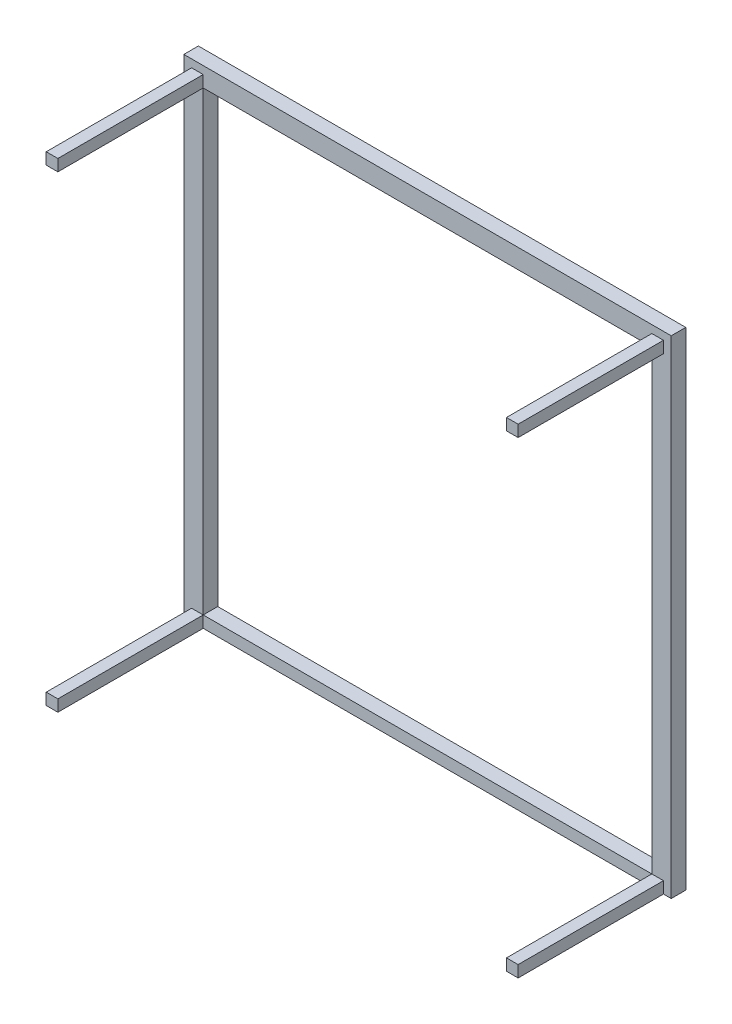
from build123d import *

# Parameters (mm, degrees)
SKETCH1_W           = 503
SKETCH1_H           = 503
SKETCH1_W_2         = 463
SKETCH1_H_2         = 471
BOSS_EXTRUDE1_DEPTH = 15
SKETCH2_W           = 12
SKETCH2_H           = 12
BOSS_EXTRUDE2_DEPTH = 200
SKETCH3_W           = 487
SKETCH3_H           = 495
CUT_EXTRUDE1_DEPTH  = 50


with BuildPart() as part:
    # Sketch1 → Boss-Extrude1 (new body)
    with BuildSketch(Plane.XY):
        with Locations((251.5, 251.5)):
            Rectangle(SKETCH1_W, SKETCH1_H)
        with Locations((251.5, 247.5)):
            Rectangle(SKETCH1_W_2, SKETCH1_H_2, mode=Mode.SUBTRACT)
    extrude(amount=BOSS_EXTRUDE1_DEPTH)

    # Sketch2 → Boss-Extrude2 (add)
    with BuildSketch(Plane.XY.offset(15)):
        with Locations((14, 489)):
            Rectangle(SKETCH2_W, SKETCH2_H)
        with Locations((489, 489)):
            Rectangle(SKETCH2_W, SKETCH2_H)
        with Locations((14, 6)):
            Rectangle(SKETCH2_W, SKETCH2_H)
        with Locations((489, 6)):
            Rectangle(SKETCH2_W, SKETCH2_H)
    extrude(amount=BOSS_EXTRUDE2_DEPTH)

    # Sketch3 → Cut-Extrude1 (cut)
    with BuildSketch(Plane.XY.offset(215)):
        with Locations((251.5, 247.5)):
            Rectangle(SKETCH3_W, SKETCH3_H)
    extrude(amount=-CUT_EXTRUDE1_DEPTH, mode=Mode.SUBTRACT)


solid = part.part
